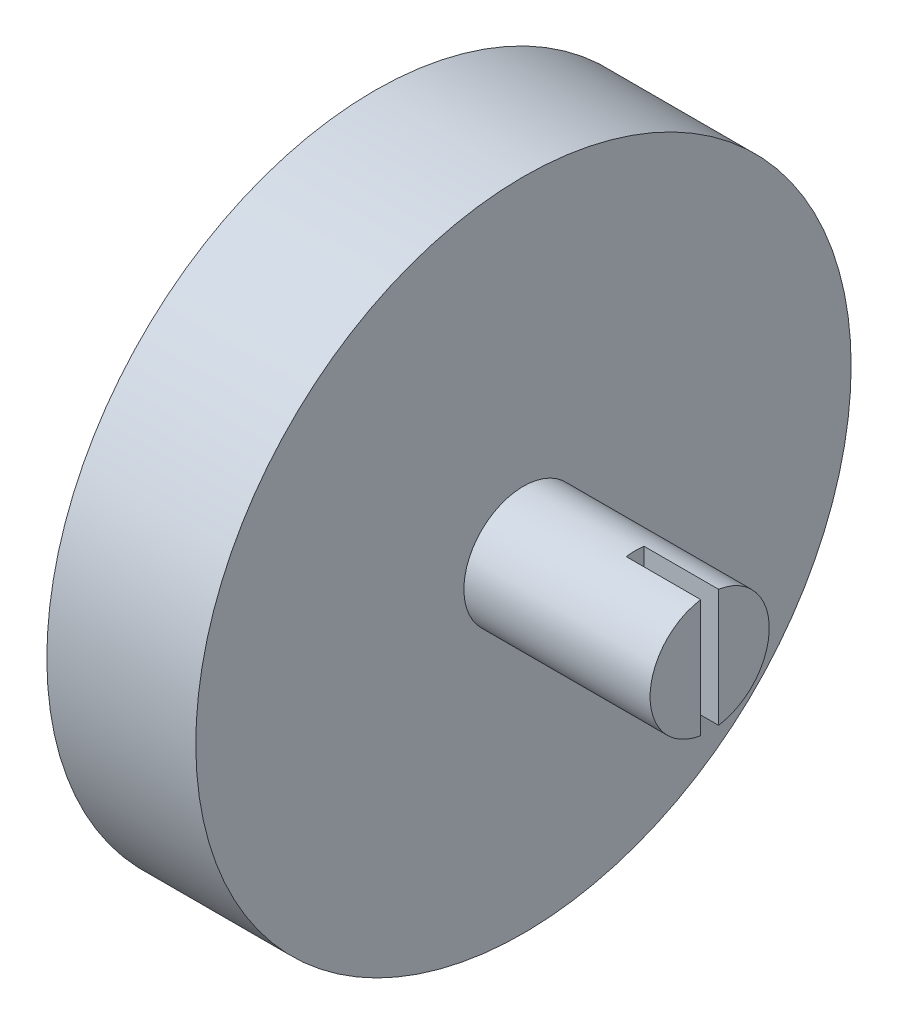
from build123d import *

# Parameters (mm, degrees)
SKETCH1_R           = 22
BOSS_EXTRUDE1_DEPTH = 10
CUT_EXTRUDE2_DEPTH  = 5.5
SKETCH15_W          = 18
SKETCH15_H          = 24.118038922
CUT_EXTRUDE3_DEPTH  = 3
SKETCH16_R          = 4
BOSS_EXTRUDE2_DEPTH = 12.5
CUT_EXTRUDE4_START  = 22.5
SKETCH8_W           = 1.2
SKETCH8_H           = 10
CUT_EXTRUDE4_DEPTH  = 5
SKETCH17_W          = 4
SKETCH17_H          = 1.75
BOSS_EXTRUDE3_DEPTH = 1
SKETCH18_W          = 4.25
SKETCH18_H          = 1.737607108
BOSS_EXTRUDE4_DEPTH = 1
SKETCH22_R          = 1.5
CUT_EXTRUDE7_DEPTH  = 7


with BuildPart() as part:
    # Sketch1 → Boss-Extrude1 (new body)
    with BuildSketch(Plane(origin=(0, 0, 0), x_dir=(0, 0, -1), z_dir=(1, 0, 0))):
        Circle(SKETCH1_R)
    extrude(amount=BOSS_EXTRUDE1_DEPTH)

    # Sketch13 → Cut-Extrude2 (cut)
    with BuildSketch(Plane(origin=(0, 0, 0), x_dir=(0, 0, -1), z_dir=(1, 0, 0))):
        with BuildLine():
            Line((-2.670420152, -16.85816067), (-2.670420152, -16.530371213))
            Line((-2.670420152, -16.530371213), (-4.762392892, -10))
            Line((-4.762392892, -10), (-4.762392892, -6.943148259))
            Line((-4.762392892, -6.943148259), (-6.5, -6.943148259))
            Line((-6.5, -6.943148259), (-6.5, 19.556851741))
            Line((-6.5, 19.556851741), (6.5, 19.556851741))
            Line((6.5, 19.556851741), (6.5, -6.943148259))
            Line((6.5, -6.943148259), (4.762392892, -6.943148259))
            Line((4.762392892, -6.943148259), (4.762392892, -10))
            Line((4.762392892, -10), (2.670420152, -16.530371213))
            Line((2.670420152, -16.530371213), (2.670420152, -16.85816067))
            Line((2.670420152, -16.85816067), (2.670420152, -21.837327131))
            ThreePointArc((2.670420152, -21.837327131), (1.836835043, -21.92318492), (1.000584871, -21.977234355))
            Line((1.000584871, -21.977234355), (0, -25.25))
            Line((0, -25.25), (-1.000584871, -21.977234355))
            ThreePointArc((-1.000584871, -21.977234355), (-1.836835043, -21.92318492), (-2.670420152, -21.837327131))
            Line((-2.670420152, -21.837327131), (-2.670420152, -16.85816067))
        make_face()
    extrude(amount=CUT_EXTRUDE2_DEPTH, mode=Mode.SUBTRACT)

    # Sketch15 → Cut-Extrude3 (cut)
    with BuildSketch(Plane.ZY):
        with Locations((0, 5.115871202)):
            Rectangle(SKETCH15_W, SKETCH15_H)
    extrude(amount=-CUT_EXTRUDE3_DEPTH, mode=Mode.SUBTRACT)

    # Sketch16 → Boss-Extrude2 (add)
    with BuildSketch(Plane(origin=(10, 0, 0), x_dir=(0, 0, -1), z_dir=(1, 0, 0))):
        Circle(SKETCH16_R)
    extrude(amount=BOSS_EXTRUDE2_DEPTH)

    # Sketch8 → Cut-Extrude4 (cut)
    with BuildSketch(Plane(origin=(0, 0, 0), x_dir=(0, 0, -1), z_dir=(1, 0, 0)).offset(CUT_EXTRUDE4_START)):
        Rectangle(SKETCH8_W, SKETCH8_H)
    extrude(amount=-CUT_EXTRUDE4_DEPTH, mode=Mode.SUBTRACT)

    # Sketch17 → Boss-Extrude3 (add)
    with BuildSketch(Plane(origin=(0, -6.943148259, 0), x_dir=(1, 0, 0), z_dir=(0, 1, 0))):
        with Locations((2, 5.637392892)):
            Rectangle(SKETCH17_W, SKETCH17_H)
    extrude(amount=BOSS_EXTRUDE3_DEPTH)

    # Sketch18 → Boss-Extrude4 (add)
    with BuildSketch(Plane(origin=(0, -6.943148259, 0), x_dir=(1, 0, 0), z_dir=(0, 1, 0))):
        with Locations((2.125, -5.631196446)):
            Rectangle(SKETCH18_W, SKETCH18_H)
    extrude(amount=BOSS_EXTRUDE4_DEPTH)

    # Sketch22 → Cut-Extrude7 (cut)
    with BuildSketch(Plane(origin=(0, 0, 0), x_dir=(0, 0, -1), z_dir=(1, 0, 0))):
        with Locations((-14, 0)):
            Circle(SKETCH22_R)
        with Locations((14, 0)):
            Circle(SKETCH22_R)
    extrude(amount=CUT_EXTRUDE7_DEPTH, mode=Mode.SUBTRACT)


solid = part.part
